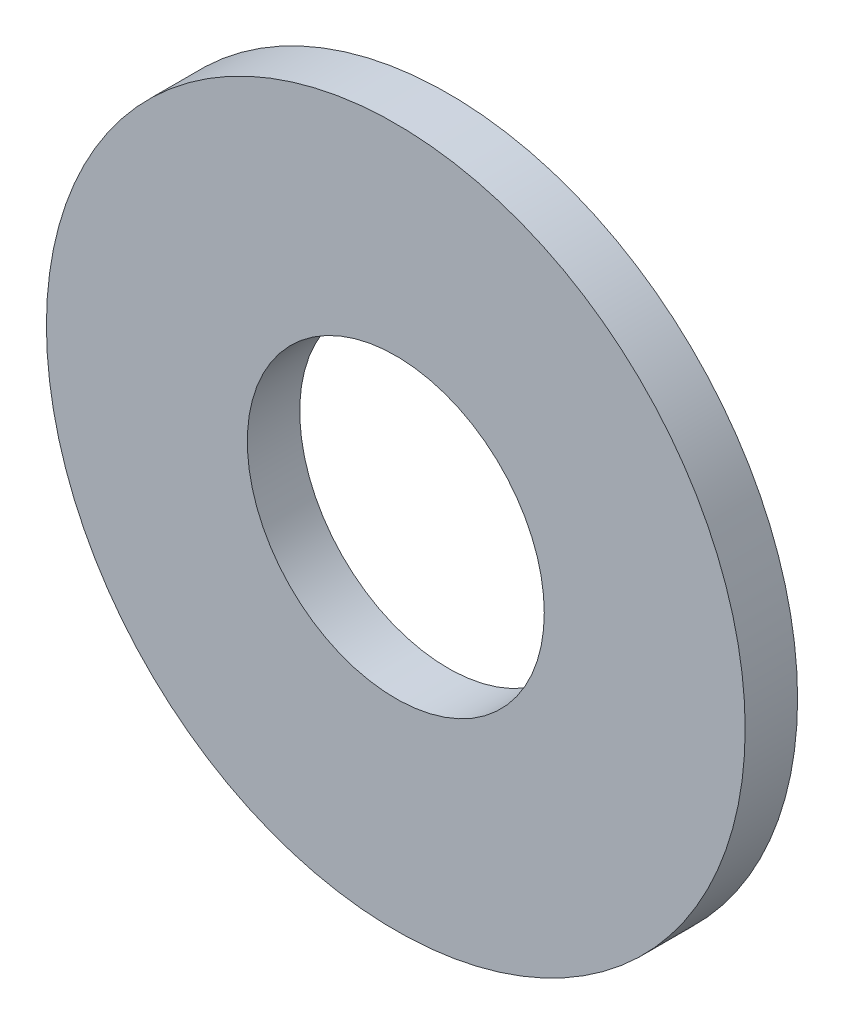
from build123d import *

# Parameters (mm, degrees)
SKETCH1_R           = 2
SKETCH1_R_2         = 0.85
BOSS_EXTRUDE1_DEPTH = 0.3


with BuildPart() as part:
    # Sketch1 → Boss-Extrude1 (new body)
    with BuildSketch(Plane.XY):
        Circle(SKETCH1_R)
        Circle(SKETCH1_R_2, mode=Mode.SUBTRACT)
    extrude(amount=BOSS_EXTRUDE1_DEPTH)


solid = part.part
